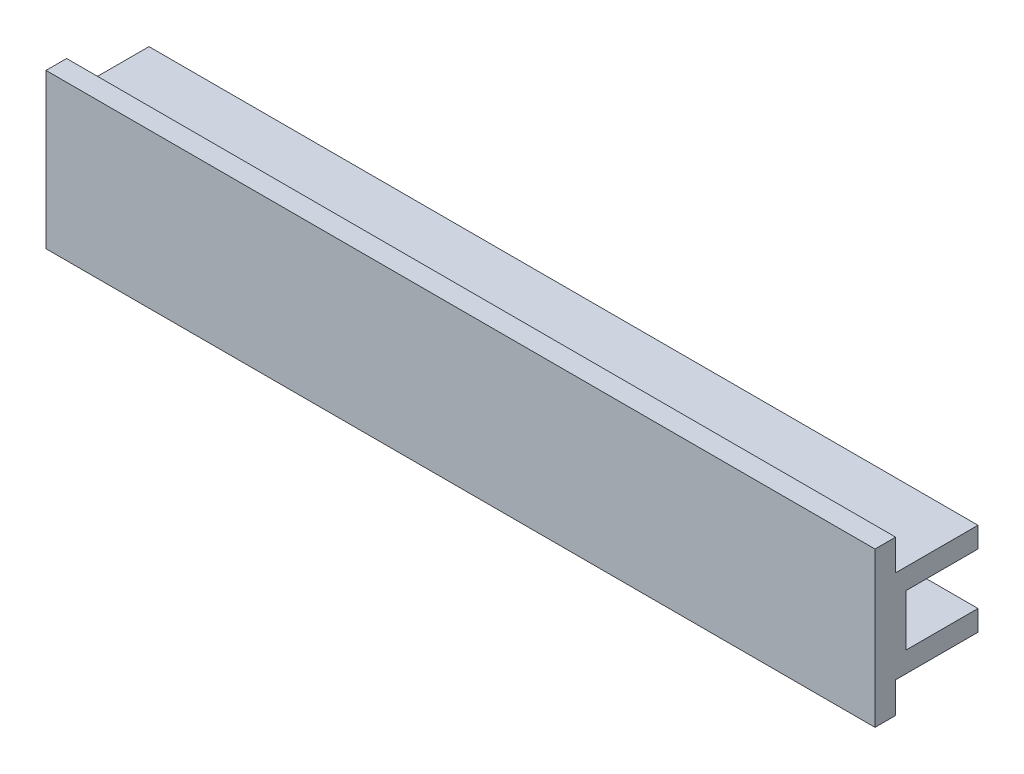
from build123d import *

# Parameters (mm, degrees)
EXTRUDE1_DEPTH = 40.25
SKETCH2_W      = 1
SKETCH2_H      = 5
EXTRUDE2_DEPTH = 22


with BuildPart() as part:
    # Sketch1 → Extrude1 (new body, symmetric)
    with BuildSketch(Plane(origin=(0, 0, 0), x_dir=(0, 0, -1), z_dir=(1, 0, 0))):
        Polygon((-3, 7.5), (-3, 4.5), (5, 4.5), (5, 2.5), (-2, 2.5), (-2, -2.5), (5, -2.5), (5, -4.5), (-3, -4.5), (-3, -7.5), (-5, -7.5), (-5, 7.5), align=None)
    extrude(amount=EXTRUDE1_DEPTH, both=True)

    # Sketch2 → Extrude2 (cut)
    with BuildSketch(Plane.ZY.offset(40.25)):
        with Locations((2.5, 0)):
            Rectangle(SKETCH2_W, SKETCH2_H)
    extrude(amount=-EXTRUDE2_DEPTH, mode=Mode.SUBTRACT)


solid = part.part
